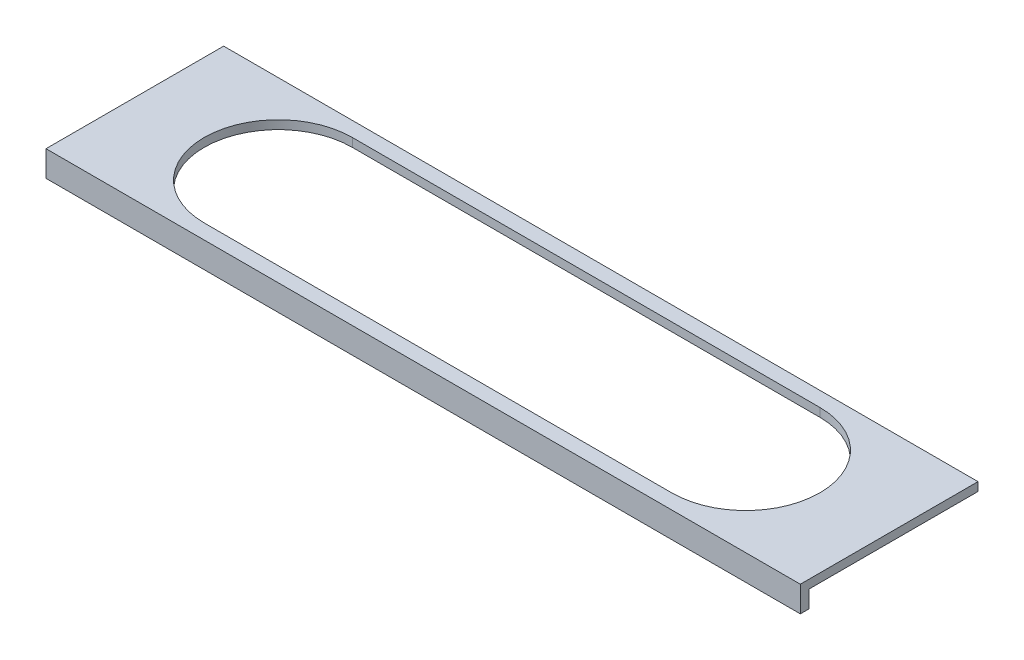
from build123d import *

# Parameters (mm, degrees)
SKETCH1_W           = 9680
SKETCH1_H           = 2280
BOSS_EXTRUDE1_DEPTH = 110
CUT_EXTRUDE1_DEPTH  = 110
SKETCH4_W           = 9680
SKETCH4_H           = 110
BOSS_EXTRUDE3_DEPTH = 220


with BuildPart() as part:
    # Sketch1 → Boss-Extrude1 (new body)
    with BuildSketch(Plane(origin=(0, 0, 0), x_dir=(1, 0, 0), z_dir=(0, 1, 0))):
        Rectangle(SKETCH1_W, SKETCH1_H)
    extrude(amount=BOSS_EXTRUDE1_DEPTH)

    # Sketch2 → Cut-Extrude1 (cut)
    with BuildSketch(Plane(origin=(0, 110, 0), x_dir=(1, 0, 0), z_dir=(0, 1, 0))):
        with BuildLine():
            Line((-3000, 950), (3000, 950))
            ThreePointArc((3000, 950), (3950, 0), (3000, -950))
            Line((3000, -950), (-3000, -950))
            ThreePointArc((-3000, -950), (-3950, 0), (-3000, 950))
        make_face()
    extrude(amount=-CUT_EXTRUDE1_DEPTH, mode=Mode.SUBTRACT)

    # Sketch4 → Boss-Extrude3 (add)
    with BuildSketch(Plane.XZ):
        with Locations((0, 1085)):
            Rectangle(SKETCH4_W, SKETCH4_H)
    extrude(amount=BOSS_EXTRUDE3_DEPTH)


solid = part.part
